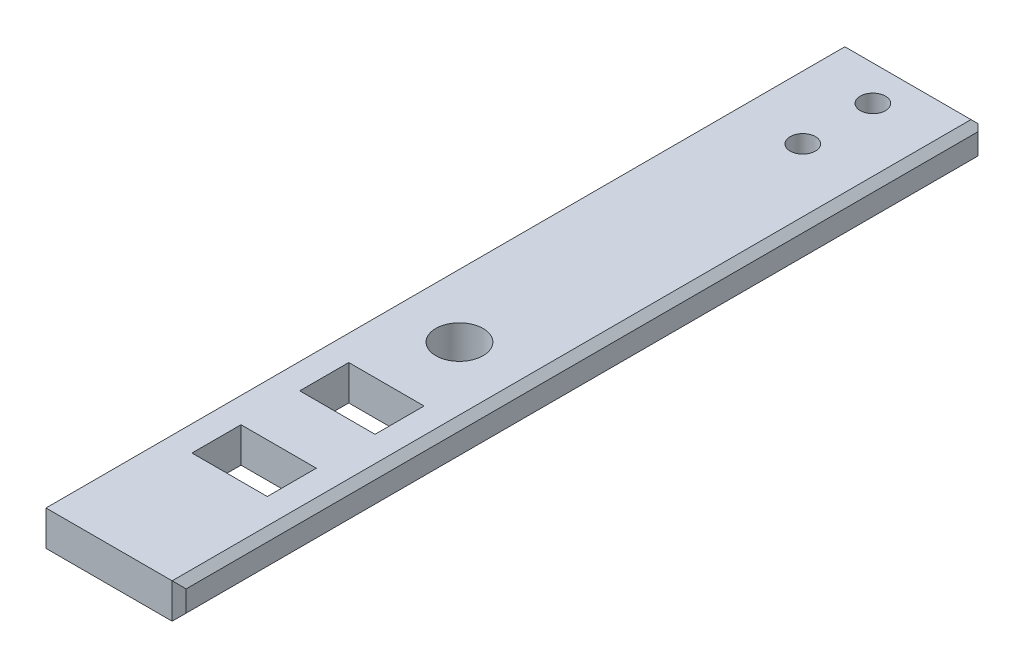
from build123d import *

# Parameters (mm, degrees)
SKETCH1_W                = 20
SKETCH1_H                = 115
BOSS_EXTRUDE1_DEPTH      = 5
CHAMFER1_SIZE            = 1
CHAMFER2_SIZE            = 1
M3_CLEARANCE_HOLE6_D     = 3.6
M3_CLEARANCE_HOLE6_DEPTH = 5
SKETCH19_W               = 10.75
SKETCH19_H               = 7
CUT_EXTRUDE3_DEPTH       = 6
SKETCH20_R               = 3.375
CUT_EXTRUDE4_DEPTH       = 10


with BuildPart() as part:
    # Sketch1 → Boss-Extrude1 (new body)
    with BuildSketch(Plane(origin=(0, 0, 0), x_dir=(1, 0, 0), z_dir=(0, 1, 0))):
        with Locations((10, 57.5)):
            Rectangle(SKETCH1_W, SKETCH1_H)
    extrude(amount=BOSS_EXTRUDE1_DEPTH)

    # Chamfer1
    chamfer1_edges = [part.edges().sort_by_distance(p)[0] for p in [
        (20, 5, -57.5),
        (0, 5, -57.5),
        (20, 0, -57.5),
        (0, 0, -57.5),
        (0, 2.5, -115),
        (20, 2.5, -115),
        (20, 2.5, 0),
        (0, 2.5, 0),
    ]]
    chamfer(chamfer1_edges, length=CHAMFER1_SIZE)

    # Chamfer2
    chamfer2_edges = [part.edges().sort_by_distance(p)[0] for p in [
        (10, 5, -115),
        (10, 0, -115),
    ]]
    chamfer(chamfer2_edges, length=CHAMFER2_SIZE)

    # M3 Clearance Hole6
    with Locations(Plane(origin=(0, 0, 0), x_dir=(-1, 0, 0), z_dir=(0, -1, 0))):
        with Locations((-10, 109), (-10, 99)):
            Hole(M3_CLEARANCE_HOLE6_D / 2, depth=M3_CLEARANCE_HOLE6_DEPTH)

    # Sketch19 → Cut-Extrude3 (cut, through all)
    with BuildSketch(Plane(origin=(0, 0, 0), x_dir=(1, 0, 0), z_dir=(0, 1, 0))):
        with Locations((10, 20.704322589)):
            Rectangle(SKETCH19_W, SKETCH19_H)
    cut_extrude3 = extrude(amount=CUT_EXTRUDE3_DEPTH, mode=Mode.SUBTRACT)

    # Mirror1: Cut-Extrude3 across plane
    add(cut_extrude3.mirror(Plane.XY.offset(-28.391822589)), mode=Mode.SUBTRACT)

    # Sketch20 → Cut-Extrude4 (cut)
    with BuildSketch(Plane(origin=(0, 5, 0), x_dir=(1, 0, 0), z_dir=(0, 1, 0))):
        with Locations((10, 50)):
            Circle(SKETCH20_R)
    extrude(amount=-CUT_EXTRUDE4_DEPTH, mode=Mode.SUBTRACT)


solid = part.part
